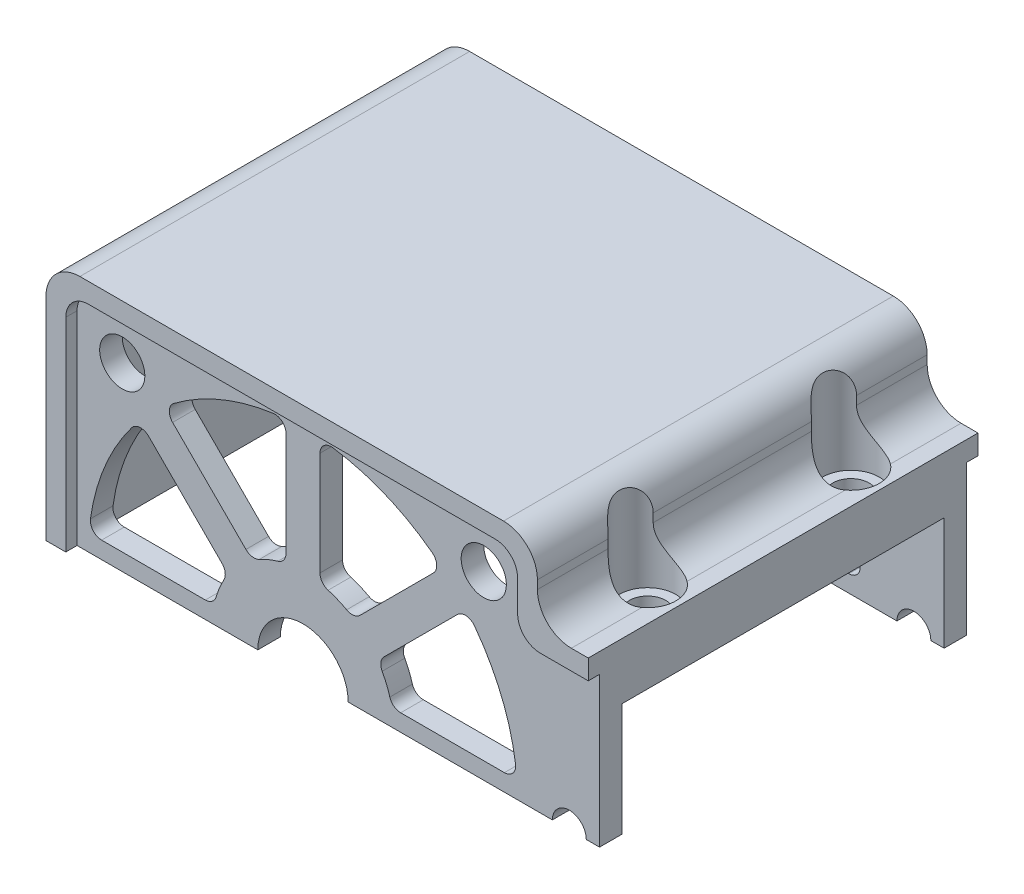
from build123d import *

# Parameters (mm, degrees)
EXTRUDE_1_DEPTH          = 28.5
EXTRUDE_2_DEPTH          = 3
EXTRUDE_3_DEPTH          = 3
CUT_EXTRUDE_1_DEPTH      = 1
CUT_EXTRUDE_2_DEPTH      = 1
SKETCH_6_R               = 2
CUT_EXTRUDE_3_DEPTH      = 33
SKETCH_7_R               = 1.6
CUT_EXTRUDE_5_DEPTH      = 6
CUT_EXTRUDE_5_DEPTH_BACK = 6
SKETCH_8_R               = 2.5
CUT_EXTRUDE_6_DEPTH      = 6
CUT_EXTRUDE_6_DEPTH_BACK = 2


with BuildPart() as part:
    # 草图1 → 凸台-拉伸1 (new body)
    with BuildSketch(Plane.XY):
        with BuildLine():
            Line((-20.25, 0), (-20.25, 17.25))
            ThreePointArc((-20.25, 17.25), (-19.371320344, 19.371320344), (-17.25, 20.25))
            Line((-17.25, 20.25), (17.25, 20.25))
            ThreePointArc((17.25, 20.25), (19.371320344, 19.371320344), (20.25, 17.25))
            Line((20.25, 17.25), (20.25, 13))
            ThreePointArc((20.25, 13), (21.128679656, 10.878679656), (23.25, 10))
            Line((23.25, 10), (26.25, 10))
            Line((26.25, 10), (26.25, 15))
            Line((26.25, 15), (24.75, 15))
            ThreePointArc((24.75, 15), (22.628679656, 15.878679656), (21.75, 18))
            Line((21.75, 18), (21.75, 18.75))
            ThreePointArc((21.75, 18.75), (20.871320344, 20.871320344), (18.75, 21.75))
            Line((18.75, 21.75), (0, 21.75))
            Line((0, 21.75), (-18.75, 21.75))
            ThreePointArc((-18.75, 21.75), (-20.871320344, 20.871320344), (-21.75, 18.75))
            Line((-21.75, 18.75), (-21.75, 0))
            Line((-21.75, 0), (-20.25, 0))
        make_face()
    extrude(amount=EXTRUDE_1_DEPTH)

    # 草图2 → 凸台-拉伸2 (add)
    with BuildSketch(Plane.XY.offset(28.5)):
        with BuildLine():
            Line((-21.75, 0), (26.25, 0))
            Line((26.25, 0), (26.25, 15))
            Line((26.25, 15), (24.75, 15))
            ThreePointArc((24.75, 15), (22.628679656, 15.878679656), (21.75, 18))
            Line((21.75, 18), (21.75, 18.75))
            ThreePointArc((21.75, 18.75), (20.871320344, 20.871320344), (18.75, 21.75))
            Line((18.75, 21.75), (-18.75, 21.75))
            ThreePointArc((-18.75, 21.75), (-20.871320344, 20.871320344), (-21.75, 18.75))
            Line((-21.75, 18.75), (-21.75, 0))
        make_face()
    extrude(amount=EXTRUDE_2_DEPTH)

    # 草图3 → 凸台-拉伸3 (add)
    with BuildSketch(Plane(origin=(0, 0, 0), x_dir=(-1, 0, 0), z_dir=(0, 0, -1))):
        with BuildLine():
            Line((21.75, 0), (-26.25, 0))
            Line((-26.25, 0), (-26.25, 15))
            Line((-26.25, 15), (-24.75, 15))
            ThreePointArc((-24.75, 15), (-22.628679656, 15.878679656), (-21.75, 18))
            Line((-21.75, 18), (-21.75, 18.75))
            ThreePointArc((-21.75, 18.75), (-20.871320344, 20.871320344), (-18.75, 21.75))
            Line((-18.75, 21.75), (18.75, 21.75))
            ThreePointArc((18.75, 21.75), (20.871320344, 20.871320344), (21.75, 18.75))
            Line((21.75, 18.75), (21.75, 0))
        make_face()
    extrude(amount=EXTRUDE_3_DEPTH)

    # 草图4 → 切除-拉伸1 (cut)
    with BuildSketch(Plane.XY.offset(31.5)):
        with BuildLine():
            Line((26.25, 13.25), (26.25, 0))
            Line((26.25, 0), (-20, 0))
            Line((-20, 0), (-20, 18))
            ThreePointArc((-20, 18), (-19.414213562, 19.414213562), (-18, 20))
            Line((-18, 20), (18, 20))
            ThreePointArc((18, 20), (19.414213562, 19.414213562), (20, 18))
            Line((20, 18), (20, 15.25))
            ThreePointArc((20, 15.25), (20.585786438, 13.835786438), (22, 13.25))
            Line((22, 13.25), (26.25, 13.25))
        make_face()
    extrude(amount=-CUT_EXTRUDE_1_DEPTH, mode=Mode.SUBTRACT)

    # 草图5 → 切除-拉伸2 (cut)
    with BuildSketch(Plane(origin=(0, 0, -3), x_dir=(-1, 0, 0), z_dir=(0, 0, -1))):
        with BuildLine():
            Line((0, 0), (20, 0))
            Line((20, 0), (20, 18))
            ThreePointArc((20, 18), (19.414213562, 19.414213562), (18, 20))
            Line((18, 20), (-18, 20))
            ThreePointArc((-18, 20), (-19.414213562, 19.414213562), (-20, 18))
            Line((-20, 18), (-20, 15.25))
            ThreePointArc((-20, 15.25), (-20.585786438, 13.835786438), (-22, 13.25))
            Line((-22, 13.25), (-26.25, 13.25))
            Line((-26.25, 13.25), (-26.25, 0))
            Line((-26.25, 0), (0, 0))
        make_face()
    extrude(amount=-CUT_EXTRUDE_2_DEPTH, mode=Mode.SUBTRACT)

    # 草图6 → 切除-拉伸3 (cut)
    with BuildSketch(Plane.XY.offset(30.5)):
        with Locations((-16, 16)):
            Circle(SKETCH_6_R)
        with Locations((16, 16)):
            Circle(SKETCH_6_R)
        with BuildLine():
            Line((22.074047969, 0), (25.074047969, 0))
            ThreePointArc((25.074047969, 0), (23.574047969, 1.5), (22.074047969, 0))
        make_face()
        with BuildLine():
            Line((-11.543902494, 13.665222838), (-5.052849459, 7.174169802))
            ThreePointArc((-5.052849459, 7.174169802), (-4.48601855, 6.891164125), (-3.86288238, 7.005579185))
            ThreePointArc((-3.86288238, 7.005579185), (-3.061467459, 7.39103626), (-2.222222222, 7.685162874))
            ThreePointArc((-2.222222222, 7.685162874), (-1.700694746, 8.04488302), (-1.5, 8.645808233))
            Line((-1.5, 8.645808233), (-1.5, 17.82554347))
            ThreePointArc((-1.5, 17.82554347), (-1.843832677, 18.580158898), (-2.638888889, 18.815851441))
            ThreePointArc((-2.638888889, 18.815851441), (-7.270985215, 17.553711118), (-11.438839919, 15.170792376))
            ThreePointArc((-11.438839919, 15.170792376), (-11.834369763, 14.441942942), (-11.543902494, 13.665222838))
        make_face()
        with BuildLine():
            Line((1.5, 17.82554347), (1.5, 8.645808233))
            ThreePointArc((1.5, 8.645808233), (1.700694746, 8.04488302), (2.222222222, 7.685162874))
            ThreePointArc((2.222222222, 7.685162874), (3.061467459, 7.39103626), (3.86288238, 7.005579185))
            ThreePointArc((3.86288238, 7.005579185), (4.48601855, 6.891164125), (5.052849459, 7.174169802))
            Line((5.052849459, 7.174169802), (11.543902494, 13.665222838))
            ThreePointArc((11.543902494, 13.665222838), (11.834369763, 14.441942942), (11.438839919, 15.170792376))
            ThreePointArc((11.438839919, 15.170792376), (7.270985215, 17.553711118), (2.638888889, 18.815851441))
            ThreePointArc((2.638888889, 18.815851441), (1.843832677, 18.580158898), (1.5, 17.82554347))
        make_face()
        with BuildLine():
            Line((13.665222838, 11.543902494), (7.174169802, 5.052849459))
            ThreePointArc((7.174169802, 5.052849459), (6.891164125, 4.48601855), (7.005579185, 3.86288238))
            ThreePointArc((7.005579185, 3.86288238), (7.39103626, 3.061467459), (7.685162874, 2.222222222))
            ThreePointArc((7.685162874, 2.222222222), (8.04488302, 1.700694746), (8.645808233, 1.5))
            Line((8.645808233, 1.5), (17.82554347, 1.5))
            ThreePointArc((17.82554347, 1.5), (18.580158898, 1.843832677), (18.815851441, 2.638888889))
            ThreePointArc((18.815851441, 2.638888889), (17.553711118, 7.270985215), (15.170792376, 11.438839919))
            ThreePointArc((15.170792376, 11.438839919), (14.441942942, 11.834369763), (13.665222838, 11.543902494))
        make_face()
        with BuildLine():
            Line((-4, 0), (4, 0))
            ThreePointArc((4, 0), (0, 4), (-4, 0))
        make_face()
        with BuildLine():
            Line((-17.82554347, 1.5), (-8.645808233, 1.5))
            ThreePointArc((-8.645808233, 1.5), (-8.04488302, 1.700694746), (-7.685162874, 2.222222222))
            ThreePointArc((-7.685162874, 2.222222222), (-7.39103626, 3.061467459), (-7.005579185, 3.86288238))
            ThreePointArc((-7.005579185, 3.86288238), (-6.891164125, 4.48601855), (-7.174169802, 5.052849459))
            Line((-7.174169802, 5.052849459), (-13.665222838, 11.543902494))
            ThreePointArc((-13.665222838, 11.543902494), (-14.441942942, 11.834369763), (-15.170792376, 11.438839919))
            ThreePointArc((-15.170792376, 11.438839919), (-17.553711118, 7.270985215), (-18.815851441, 2.638888889))
            ThreePointArc((-18.815851441, 2.638888889), (-18.580158898, 1.843832677), (-17.82554347, 1.5))
        make_face()
    extrude(amount=-CUT_EXTRUDE_3_DEPTH, mode=Mode.SUBTRACT)

    # 草图7 → 切除-拉伸5 (cut, two sides)
    with BuildSketch(Plane(origin=(0, 15, 0), x_dir=(1, 0, 0), z_dir=(0, 1, 0))) as cut_extrude_5_sk:
        with Locations((23.25, -5.25)):
            Circle(SKETCH_7_R)
        with Locations((23.25, -23.25)):
            Circle(SKETCH_7_R)
    extrude(amount=CUT_EXTRUDE_5_DEPTH, mode=Mode.SUBTRACT)
    extrude(cut_extrude_5_sk.sketch, amount=-CUT_EXTRUDE_5_DEPTH_BACK, mode=Mode.SUBTRACT)

    # 草图8 → 切除-拉伸6 (cut, two sides)
    with BuildSketch(Plane(origin=(0, 15, 0), x_dir=(1, 0, 0), z_dir=(0, 1, 0))) as cut_extrude_6_sk:
        with Locations((23.25, -5.25)):
            Circle(SKETCH_8_R)
        with Locations((23.25, -23.25)):
            Circle(SKETCH_8_R)
    extrude(amount=CUT_EXTRUDE_6_DEPTH, mode=Mode.SUBTRACT)
    extrude(cut_extrude_6_sk.sketch, amount=-CUT_EXTRUDE_6_DEPTH_BACK, mode=Mode.SUBTRACT)


solid = part.part
